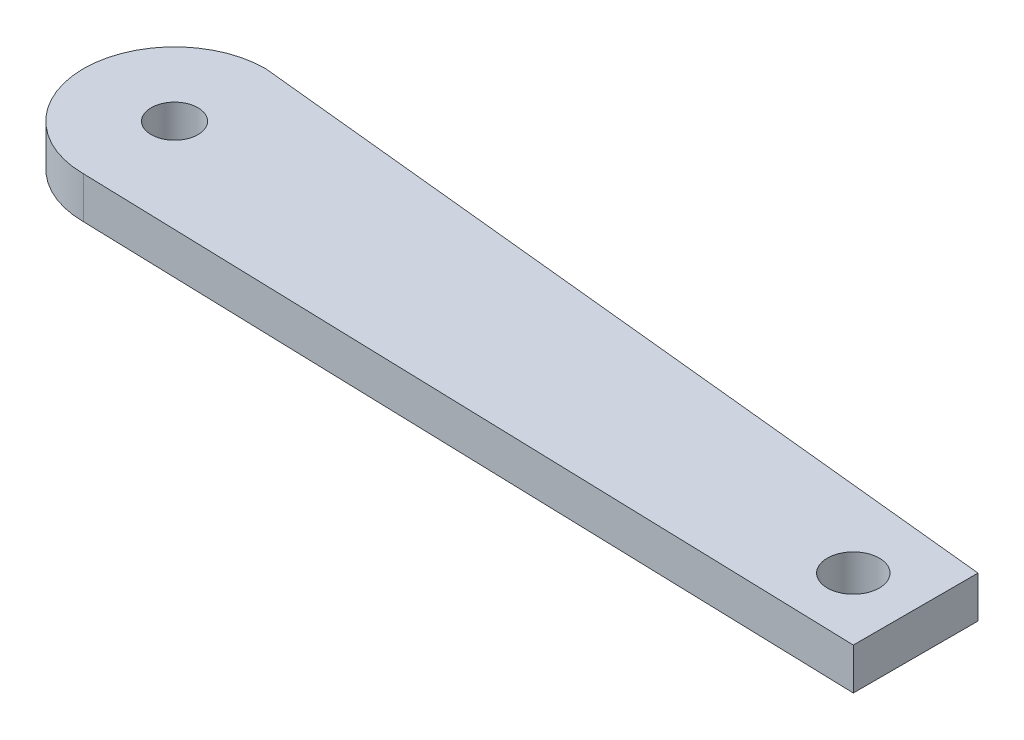
from build123d import *

# Parameters (mm, degrees)
SKETCH1_R           = 2.5
SKETCH1_R_2         = 2.25
BOSS_EXTRUDE1_DEPTH = 4


with BuildPart() as part:
    # Sketch1 → Boss-Extrude1 (new body)
    with BuildSketch(Plane(origin=(0, 0, 0), x_dir=(1, 0, 0), z_dir=(0, 1, 0))):
        with BuildLine():
            Line((1.764581835, 8.584003487), (0, 8.763496159))
            ThreePointArc((0, 8.763496159), (-8.763496159, 0), (0, -8.763496159))
            Line((0, -8.763496159), (76.322471515, -11))
            Line((76.322471515, -11), (76.322471515, 1))
            Line((76.322471515, 1), (1.764581835, 8.584003487))
        make_face()
        with Locations((70.322471515, -5)):
            Circle(SKETCH1_R, mode=Mode.SUBTRACT)
        Circle(SKETCH1_R_2, mode=Mode.SUBTRACT)
    extrude(amount=BOSS_EXTRUDE1_DEPTH)


solid = part.part
